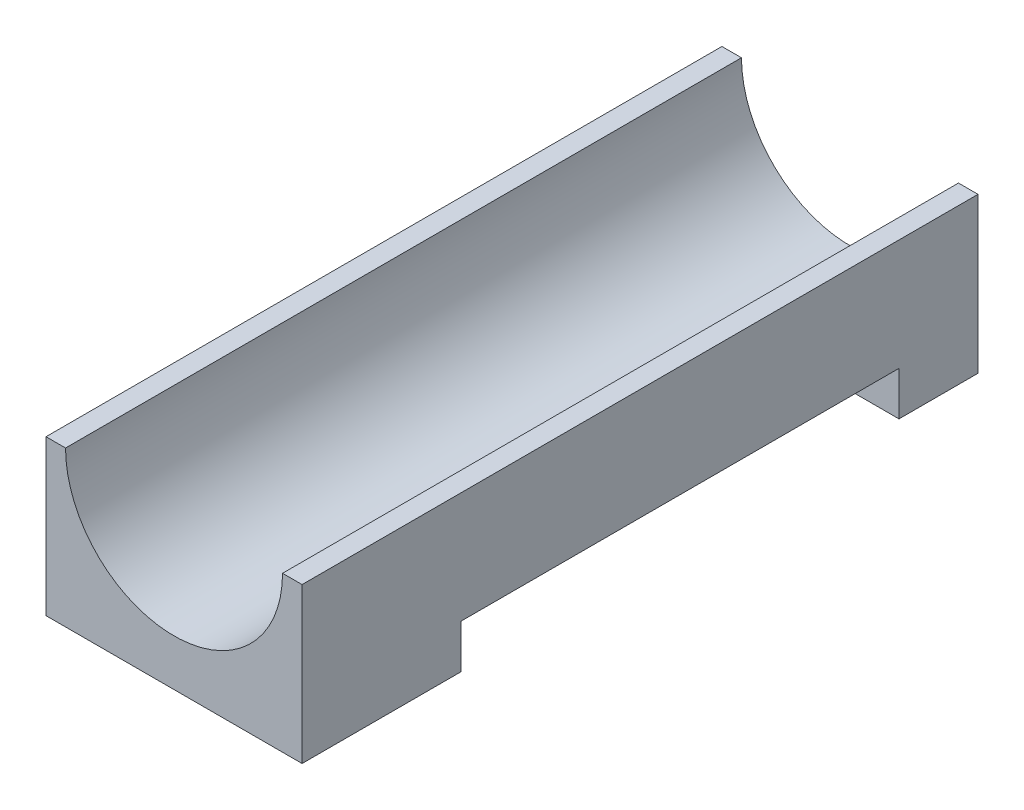
from build123d import *

# Parameters (mm, degrees)
ESQUISSE1_W             = 38
ESQUISSE1_H             = 23
BOSS_EXTRU_1_DEPTH      = 100.3
ESQUISSE4_R             = 16.1
ENL_V_MAT_EXTRU_1_DEPTH = 101.3
ESQUISSE5_W             = 65
ESQUISSE5_H             = 6.5
ENL_V_MAT_EXTRU_2_DEPTH = 39


with BuildPart() as part:
    # Esquisse1 → Boss.-Extru.1 (new body)
    with BuildSketch(Plane.XY):
        with Locations((19, 11.5)):
            Rectangle(ESQUISSE1_W, ESQUISSE1_H)
    extrude(amount=BOSS_EXTRU_1_DEPTH)

    # Esquisse4 → Enlèv. mat.-Extru.1 (cut, through all)
    with BuildSketch(Plane.XY):
        with Locations((19, 23)):
            Circle(ESQUISSE4_R)
    extrude(amount=ENL_V_MAT_EXTRU_1_DEPTH, mode=Mode.SUBTRACT)

    # Esquisse5 → Enlèv. mat.-Extru.2 (cut, through all)
    with BuildSketch(Plane(origin=(0, 0, 0), x_dir=(0, 0, -1), z_dir=(1, 0, 0))):
        with Locations((-44.225007926, 3.25)):
            Rectangle(ESQUISSE5_W, ESQUISSE5_H)
    extrude(amount=ENL_V_MAT_EXTRU_2_DEPTH, mode=Mode.SUBTRACT)


solid = part.part
